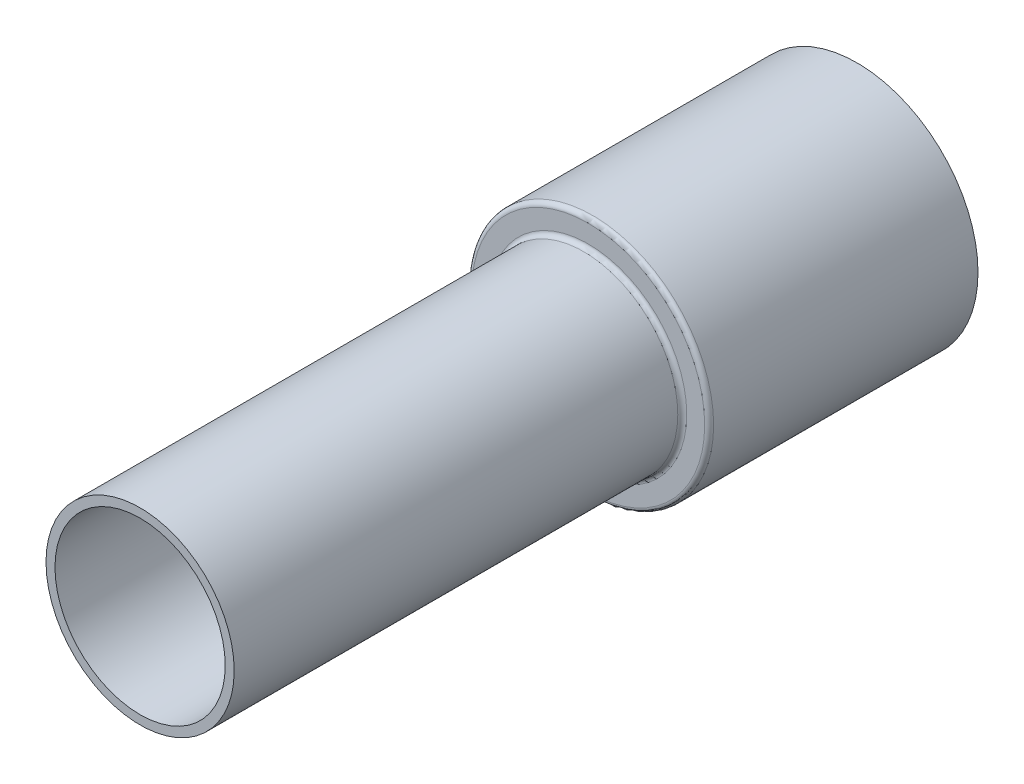
from build123d import *


with BuildPart() as part:
    # Sketch1 → Revolve4 (revolve)
    with BuildSketch(Plane(origin=(0, 0, 0), x_dir=(0, 0, -1), z_dir=(1, 0, 0))):
        with BuildLine():
            Line((50, 13), (50, 11))
            ThreePointArc((50, 11), (49.853553391, 10.646446609), (49.5, 10.5))
            Line((49.5, 10.5), (0, 10.5))
            Line((0, 10.5), (0, 9.5))
            Line((0, 9.5), (50.5, 9.5))
            ThreePointArc((50.5, 9.5), (50.853553391, 9.646446609), (51, 10))
            Line((51, 10), (51, 12))
            ThreePointArc((51, 12), (51.146446609, 12.353553391), (51.5, 12.5))
            Line((51.5, 12.5), (80, 12.5))
            Line((80, 12.5), (80, 13.5))
            Line((80, 13.5), (50.5, 13.5))
            ThreePointArc((50.5, 13.5), (50.146446609, 13.353553391), (50, 13))
        make_face()
    revolve(axis=Axis((0, 0, 0), (0, 0, -1)))


solid = part.part
